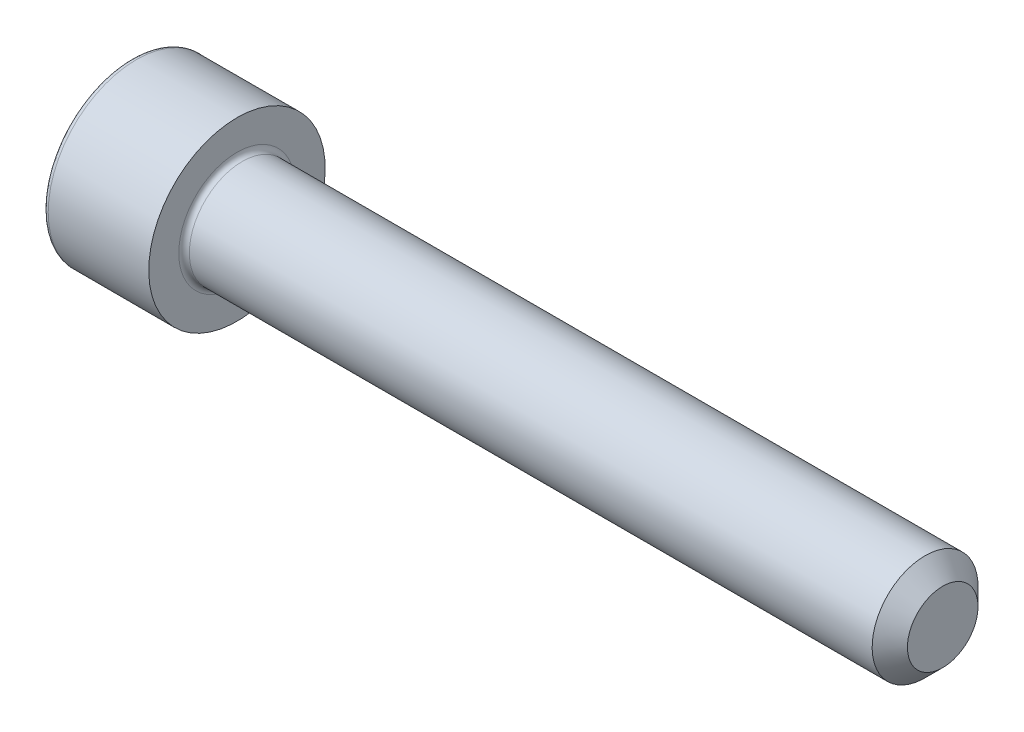
from build123d import *

# Parameters (mm, degrees)
CUT_EXTRUDE_1_DEPTH = 2.5
FILLET_1_R          = 0.3
CHAMFER_1_SIZE      = 1


with BuildPart() as part:
    # Эскиз1 → Повернуть1 (revolve)
    with BuildSketch(Plane.XY):
        Polygon((0, 0), (0, 5), (6, 5), (6, 3), (46, 3), (46, 0), align=None)
    revolve(axis=Axis((46, 0, 0), (-1, 0, 0)))

    # Эскиз2 → Вырез-Вытянуть1 (cut)
    with BuildSketch(Plane.ZY):
        Polygon((-1.443375673, 2.5), (-2.886751346, 0), (-1.443375673, -2.5), (1.443375673, -2.5), (2.886751346, 0), (1.443375673, 2.5), align=None)
    extrude(amount=-CUT_EXTRUDE_1_DEPTH, mode=Mode.SUBTRACT)

    # Скругление1
    fillet_1_edges = [part.edges().sort_by_distance(p)[0] for p in [
        (6, -3, 0),
        (0, -5, 0),
    ]]
    fillet(fillet_1_edges, radius=FILLET_1_R)

    # Фаска1
    chamfer_1_edges = [part.edges().sort_by_distance(p)[0] for p in [
        (46, -3, 0),
    ]]
    chamfer(chamfer_1_edges, length=CHAMFER_1_SIZE)


solid = part.part
